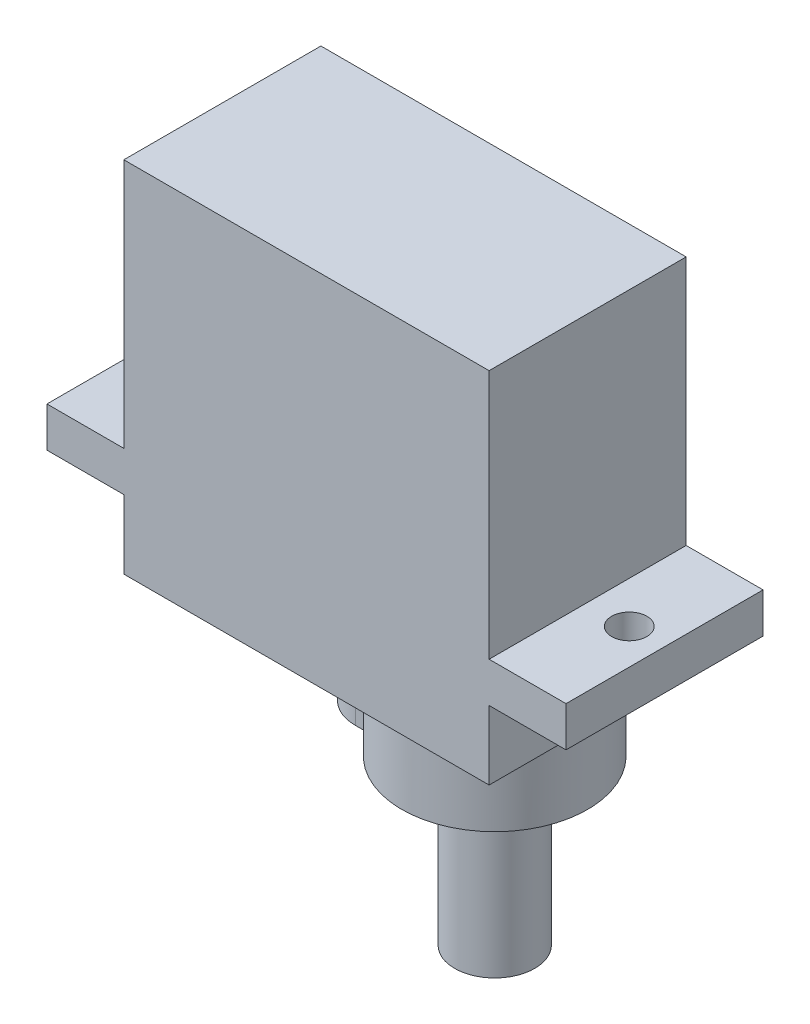
from build123d import *

# Parameters (mm, degrees)
BOSS_EXTRUDE1_DEPTH = 12.3
BOSS_EXTRUDE2_DEPTH = 4.4
SKETCH3_R           = 1.1
CUT_EXTRUDE1_DEPTH  = 8
SKETCH_1_R          = 2.5
EXTRUDE_1_DEPTH     = 10.240649244


with BuildPart() as part:
    # Sketch1 → Boss-Extrude1 (new body)
    with BuildSketch(Plane.XY):
        Polygon((-16.2, 0), (-11.4, 0), (-11.4, -4.3), (11.4, -4.3), (11.4, 0), (16.2, 0), (16.2, 2.5), (11.4, 2.5), (11.4, 18.1), (-11.4, 18.1), (-11.4, 2.5), (-16.2, 2.5), align=None)
    extrude(amount=BOSS_EXTRUDE1_DEPTH)

    # Sketch2 → Boss-Extrude2 (add)
    with BuildSketch(Plane.XZ.offset(4.3)):
        with BuildLine():
            Line((-0.4, 8.85), (0.466774893, 8.85))
            ThreePointArc((0.466774893, 8.85), (11.4, 6.15), (0.466774893, 3.45))
            Line((0.466774893, 3.45), (-0.4, 3.45))
            ThreePointArc((-0.4, 3.45), (-3.1, 6.15), (-0.4, 8.85))
        make_face()
    extrude(amount=BOSS_EXTRUDE2_DEPTH)

    # Sketch3 → Cut-Extrude1 (cut)
    with BuildSketch(Plane(origin=(0, 2.5, 0), x_dir=(1, 0, 0), z_dir=(0, 1, 0))):
        with Locations((-14, -6.15)):
            Circle(SKETCH3_R)
        with Locations((14, -6.15)):
            Circle(SKETCH3_R)
    extrude(amount=-CUT_EXTRUDE1_DEPTH, mode=Mode.SUBTRACT)


with BuildPart() as body_2:
    # 草圖1 → 填料-伸長1 (new body)
    with BuildSketch(Plane(origin=(0, -8.7, 0), x_dir=(-1, 0, 0), z_dir=(0, -1, 0))):
        with Locations((-5.6, -6.15)):
            Circle(SKETCH_1_R)
    extrude(amount=EXTRUDE_1_DEPTH)


solid = Compound([part.part, body_2.part])
